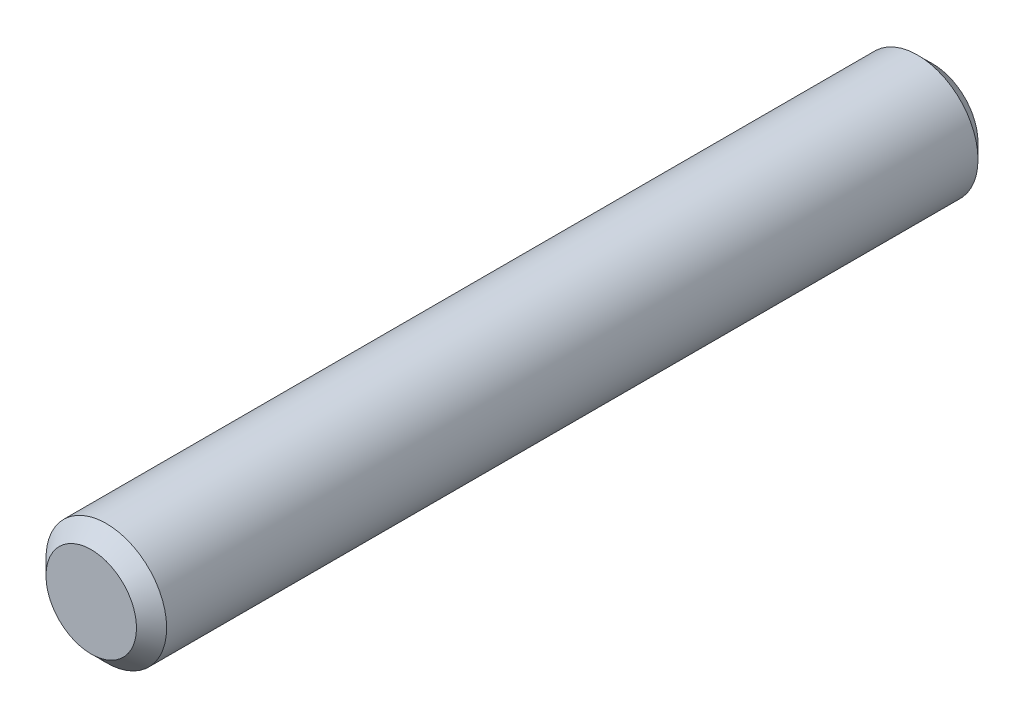
from build123d import *

# Parameters (mm, degrees)
BOSS_EXTRUDE1_DEPTH      = 35.433
BOSS_EXTRUDE1_DEPTH_BACK = 35.433
SKETCH1_R                = 5.08
CHAMFER1_SIZE            = 1.27


with BuildPart() as part:
    # Sketch1 → Boss-Extrude1 (new, two sides: drawn at the far end of the back side and taken through both)
    with BuildSketch(Plane.XY.offset(-BOSS_EXTRUDE1_DEPTH_BACK)):
        Circle(SKETCH1_R)
    extrude(amount=BOSS_EXTRUDE1_DEPTH + BOSS_EXTRUDE1_DEPTH_BACK)

    # Chamfer1
    chamfer1_edges = [part.edges().sort_by_distance(p)[0] for p in [
        (-5.08, 0, 35.433),
        (-5.08, 0, -35.433),
    ]]
    chamfer(chamfer1_edges, length=CHAMFER1_SIZE)


solid = part.part
